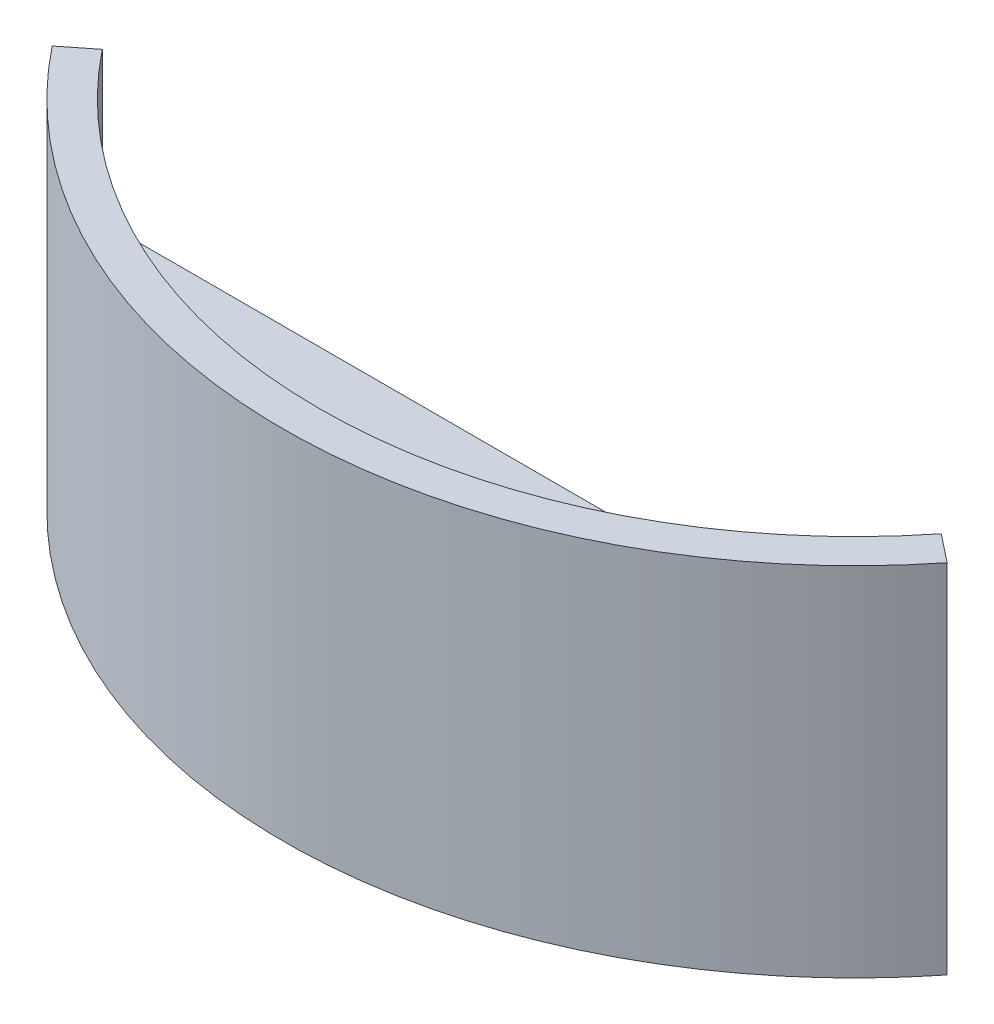
from build123d import *

# Parameters (mm, degrees)
BOSS_EXTRUDE1_DEPTH = 10
BOSS_EXTRUDE2_DEPTH = 2


with BuildPart() as part:
    # Sketch1 → Boss-Extrude1 (new body, symmetric)
    with BuildSketch(Plane(origin=(0, 0, 0), x_dir=(1, 0, 0), z_dir=(0, 1, 0))):
        with BuildLine():
            Line((-25.066666667, 10.108740054), (-23.5, 11.351943801))
            ThreePointArc((-23.5, 11.351943801), (0, 0), (23.5, 11.351943801))
            Line((23.5, 11.351943801), (25.066666667, 10.108740054))
            ThreePointArc((25.066666667, 10.108740054), (0, -2), (-25.066666667, 10.108740054))
        make_face()
    extrude(amount=BOSS_EXTRUDE1_DEPTH, both=True)

    # Sketch2 → Boss-Extrude2 (add, symmetric)
    with BuildSketch(Plane(origin=(0, 0, 0), x_dir=(1, 0, 0), z_dir=(0, 1, 0))):
        with BuildLine():
            Line((-23.216373532, 11), (23.216373532, 11))
            ThreePointArc((23.216373532, 11), (0, 0), (-23.216373532, 11))
        make_face()
    extrude(amount=BOSS_EXTRUDE2_DEPTH, both=True)


solid = part.part
